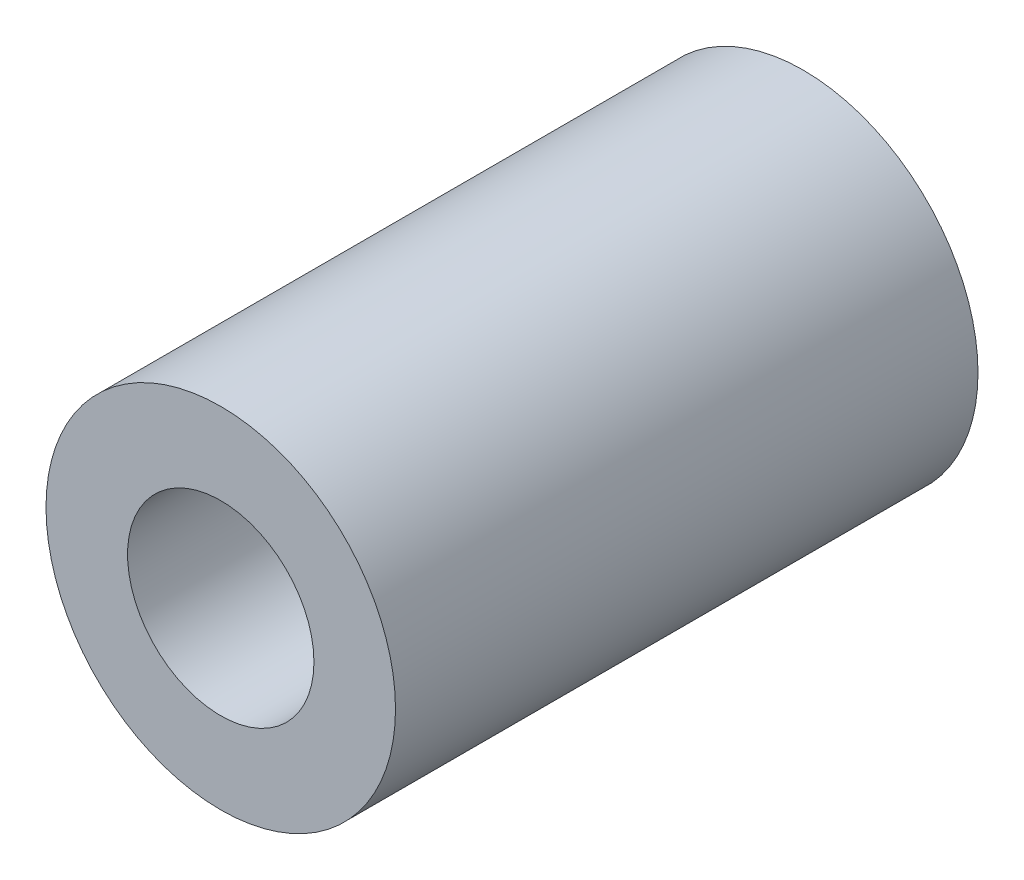
from build123d import *

# Parameters (mm, degrees)
SKETCH1_R      = 3
SKETCH1_R_2    = 1.6
EXTRUDE1_DEPTH = 5


with BuildPart() as part:
    # Sketch1 → Extrude1 (new body, symmetric)
    with BuildSketch(Plane.XY):
        Circle(SKETCH1_R)
        Circle(SKETCH1_R_2, mode=Mode.SUBTRACT)
    extrude(amount=EXTRUDE1_DEPTH, both=True)


solid = part.part
